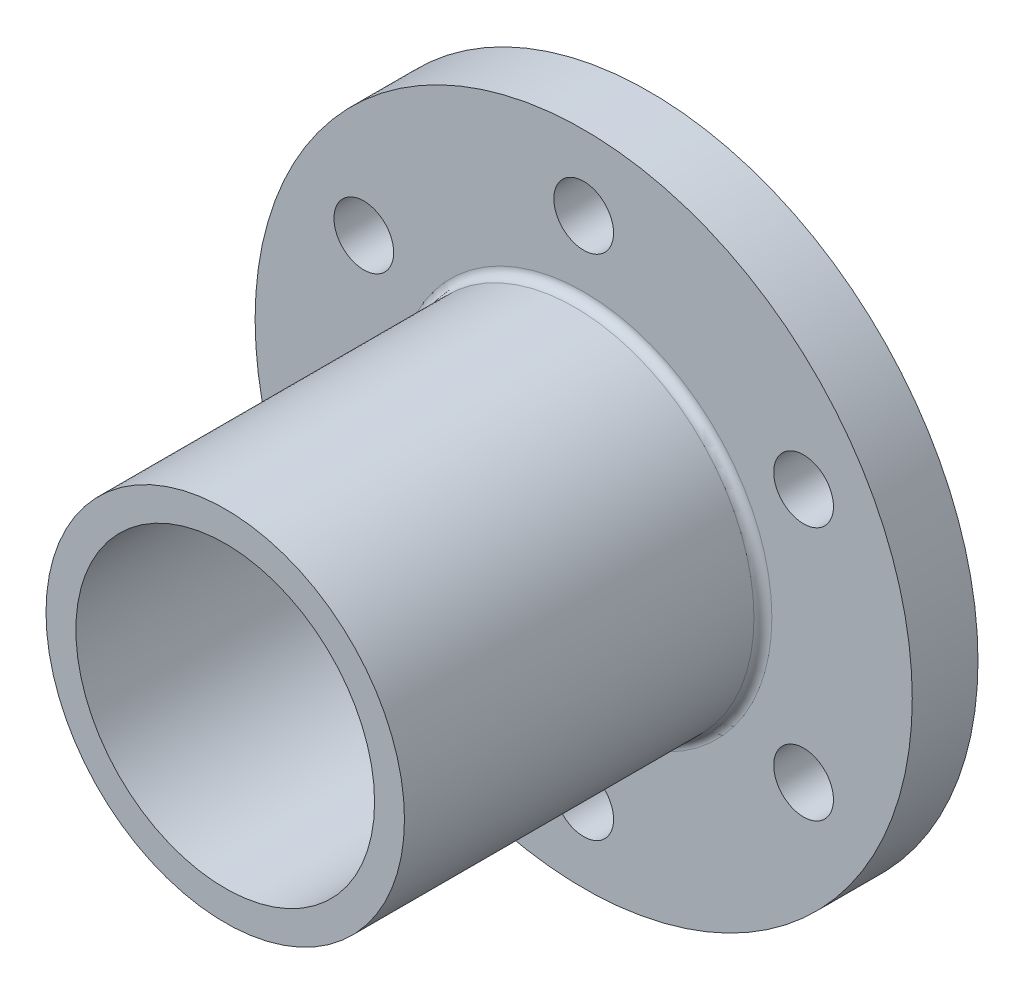
from build123d import *

# Parameters (mm, degrees)
SKETCH2_R           = 110
BOSS_EXTRUDE1_DEPTH = 22
SKETCH3_R           = 60
BOSS_EXTRUDE2_DEPTH = 120
SKETCH4_R           = 50
CUT_EXTRUDE1_DEPTH  = 143
SKETCH5_R           = 10
CUT_EXTRUDE2_DEPTH  = 23
FILLET1_R           = 3


with BuildPart() as part:
    # Sketch2 → Boss-Extrude1 (new body)
    with BuildSketch(Plane.XY):
        Circle(SKETCH2_R)
    extrude(amount=BOSS_EXTRUDE1_DEPTH)

    # Sketch3 → Boss-Extrude2 (add)
    with BuildSketch(Plane.XY.offset(22)):
        Circle(SKETCH3_R)
    extrude(amount=BOSS_EXTRUDE2_DEPTH)

    # Sketch4 → Cut-Extrude1 (cut, through all)
    with BuildSketch(Plane.XY.offset(142)):
        Circle(SKETCH4_R)
    extrude(amount=-CUT_EXTRUDE1_DEPTH, mode=Mode.SUBTRACT)

    # Sketch5 → Cut-Extrude2 (cut, through all)
    with BuildSketch(Plane.XY.offset(22)):
        with Locations((0, 85)):
            Circle(SKETCH5_R)
        with Locations((73.612159322, 42.5)):
            Circle(SKETCH5_R)
        with Locations((73.612159322, -42.5)):
            Circle(SKETCH5_R)
        with Locations((0, -85)):
            Circle(SKETCH5_R)
        with Locations((-73.612159322, -42.5)):
            Circle(SKETCH5_R)
        with Locations((-73.612159322, 42.5)):
            Circle(SKETCH5_R)
    extrude(amount=-CUT_EXTRUDE2_DEPTH, mode=Mode.SUBTRACT)

    # Fillet1
    fillet1_edges = [part.edges().sort_by_distance(p)[0] for p in [
        (-60, 0, 22),
    ]]
    fillet(fillet1_edges, radius=FILLET1_R)


solid = part.part
